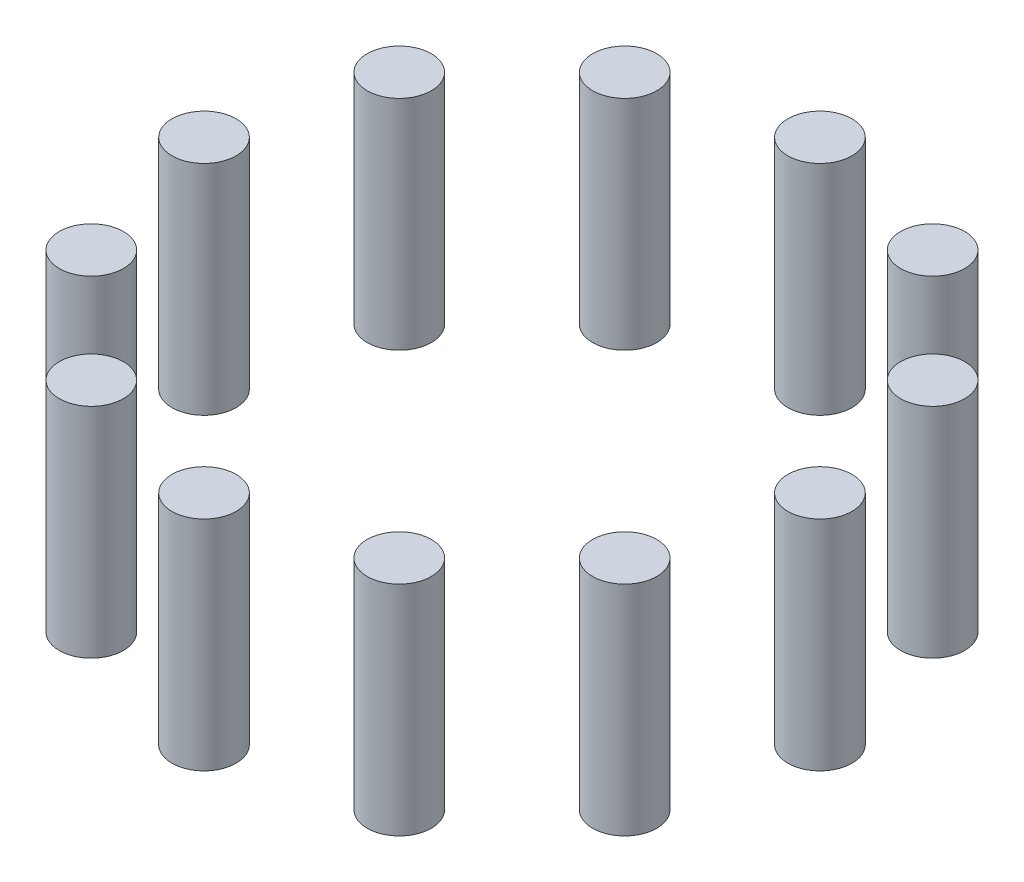
from build123d import *

# Parameters (mm, degrees)
SKETCH1_R              = 2.5
BOSS_EXTRUDE1_DEPTH    = 17
BOSS_EXTRUDE1_2_DEPTH  = 17
BOSS_EXTRUDE1_3_DEPTH  = 17
BOSS_EXTRUDE1_4_DEPTH  = 17
BOSS_EXTRUDE1_5_DEPTH  = 17
BOSS_EXTRUDE1_6_DEPTH  = 17
BOSS_EXTRUDE1_7_DEPTH  = 17
BOSS_EXTRUDE1_8_DEPTH  = 17
BOSS_EXTRUDE1_9_DEPTH  = 17
BOSS_EXTRUDE1_10_DEPTH = 17
BOSS_EXTRUDE1_11_DEPTH = 17
BOSS_EXTRUDE1_12_DEPTH = 17


with BuildPart() as part:
    # Sketch1 → Boss-Extrude1 (new body)
    with BuildSketch(Plane(origin=(0, 0, 0), x_dir=(1, 0, 0), z_dir=(0, 1, 0))):
        with Locations((0, 24)):
            Circle(SKETCH1_R)
    extrude(amount=BOSS_EXTRUDE1_DEPTH)


with BuildPart() as body_2:
    # Sketch1 → Boss-Extrude1 2 (new body)
    with BuildSketch(Plane(origin=(0, 0, 0), x_dir=(1, 0, 0), z_dir=(0, 1, 0))):
        with Locations((12, 20.784609691)):
            Circle(SKETCH1_R)
    extrude(amount=BOSS_EXTRUDE1_2_DEPTH)


with BuildPart() as body_3:
    # Sketch1 → Boss-Extrude1 3 (new body)
    with BuildSketch(Plane(origin=(0, 0, 0), x_dir=(1, 0, 0), z_dir=(0, 1, 0))):
        with Locations((20.784609691, 12)):
            Circle(SKETCH1_R)
    extrude(amount=BOSS_EXTRUDE1_3_DEPTH)


with BuildPart() as body_4:
    # Sketch1 → Boss-Extrude1 4 (new body)
    with BuildSketch(Plane(origin=(0, 0, 0), x_dir=(1, 0, 0), z_dir=(0, 1, 0))):
        with Locations((24, 0)):
            Circle(SKETCH1_R)
    extrude(amount=BOSS_EXTRUDE1_4_DEPTH)


with BuildPart() as body_5:
    # Sketch1 → Boss-Extrude1 5 (new body)
    with BuildSketch(Plane(origin=(0, 0, 0), x_dir=(1, 0, 0), z_dir=(0, 1, 0))):
        with Locations((20.784609691, -12)):
            Circle(SKETCH1_R)
    extrude(amount=BOSS_EXTRUDE1_5_DEPTH)


with BuildPart() as body_6:
    # Sketch1 → Boss-Extrude1 6 (new body)
    with BuildSketch(Plane(origin=(0, 0, 0), x_dir=(1, 0, 0), z_dir=(0, 1, 0))):
        with Locations((12, -20.784609691)):
            Circle(SKETCH1_R)
    extrude(amount=BOSS_EXTRUDE1_6_DEPTH)


with BuildPart() as body_7:
    # Sketch1 → Boss-Extrude1 7 (new body)
    with BuildSketch(Plane(origin=(0, 0, 0), x_dir=(1, 0, 0), z_dir=(0, 1, 0))):
        with Locations((0, -24)):
            Circle(SKETCH1_R)
    extrude(amount=BOSS_EXTRUDE1_7_DEPTH)


with BuildPart() as body_8:
    # Sketch1 → Boss-Extrude1 8 (new body)
    with BuildSketch(Plane(origin=(0, 0, 0), x_dir=(1, 0, 0), z_dir=(0, 1, 0))):
        with Locations((-12, -20.784609691)):
            Circle(SKETCH1_R)
    extrude(amount=BOSS_EXTRUDE1_8_DEPTH)


with BuildPart() as body_9:
    # Sketch1 → Boss-Extrude1 9 (new body)
    with BuildSketch(Plane(origin=(0, 0, 0), x_dir=(1, 0, 0), z_dir=(0, 1, 0))):
        with Locations((-20.784609691, -12)):
            Circle(SKETCH1_R)
    extrude(amount=BOSS_EXTRUDE1_9_DEPTH)


with BuildPart() as body_10:
    # Sketch1 → Boss-Extrude1 10 (new body)
    with BuildSketch(Plane(origin=(0, 0, 0), x_dir=(1, 0, 0), z_dir=(0, 1, 0))):
        with Locations((-24, 0)):
            Circle(SKETCH1_R)
    extrude(amount=BOSS_EXTRUDE1_10_DEPTH)


with BuildPart() as body_11:
    # Sketch1 → Boss-Extrude1 11 (new body)
    with BuildSketch(Plane(origin=(0, 0, 0), x_dir=(1, 0, 0), z_dir=(0, 1, 0))):
        with Locations((-20.784609691, 12)):
            Circle(SKETCH1_R)
    extrude(amount=BOSS_EXTRUDE1_11_DEPTH)


with BuildPart() as body_12:
    # Sketch1 → Boss-Extrude1 12 (new body)
    with BuildSketch(Plane(origin=(0, 0, 0), x_dir=(1, 0, 0), z_dir=(0, 1, 0))):
        with Locations((-12, 20.784609691)):
            Circle(SKETCH1_R)
    extrude(amount=BOSS_EXTRUDE1_12_DEPTH)


solid = Compound([part.part, body_2.part, body_3.part, body_4.part, body_5.part, body_6.part, body_7.part, body_8.part, body_9.part, body_10.part, body_11.part, body_12.part])
